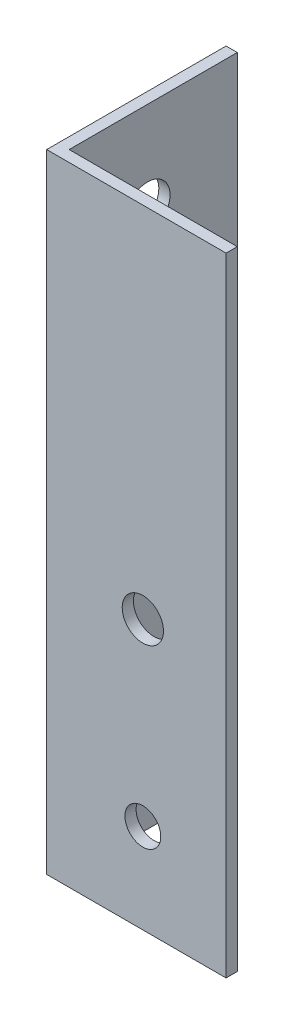
from build123d import *

# Parameters (mm, degrees)
BOSS_EXTRUDE1_DEPTH = 88.9
SKETCH2_R           = 2.54
SKETCH2_R_2         = 2.922857965
CUT_EXTRUDE1_DEPTH  = 88.9
SKETCH3_R           = 3.175
CUT_EXTRUDE2_DEPTH  = 88.9


with BuildPart() as part:
    # Sketch1 → Boss-Extrude1 (new body)
    with BuildSketch(Plane(origin=(0, 0, 0), x_dir=(1, 0, 0), z_dir=(0, 1, 0))):
        Polygon((0, 25.4), (0, 0), (25.4, 0), (25.4, 1.5875), (1.5875, 1.5875), (1.5875, 25.4), align=None)
    extrude(amount=BOSS_EXTRUDE1_DEPTH)

    # Sketch2 → Cut-Extrude1 (cut)
    with BuildSketch(Plane(origin=(0, 0, -1.5875), x_dir=(-1, 0, 0), z_dir=(0, 0, -1))):
        with Locations((-13.612947448, 12.7)):
            Circle(SKETCH2_R)
        with Locations((-13.612947448, 38.1)):
            Circle(SKETCH2_R_2)
    extrude(amount=-CUT_EXTRUDE1_DEPTH, mode=Mode.SUBTRACT)

    # Sketch3 → Cut-Extrude2 (cut)
    with BuildSketch(Plane(origin=(1.5875, 0, 0), x_dir=(0, 0, -1), z_dir=(1, 0, 0))):
        with Locations((12.7, 76.2)):
            Circle(SKETCH3_R)
    extrude(amount=-CUT_EXTRUDE2_DEPTH, mode=Mode.SUBTRACT)


solid = part.part
